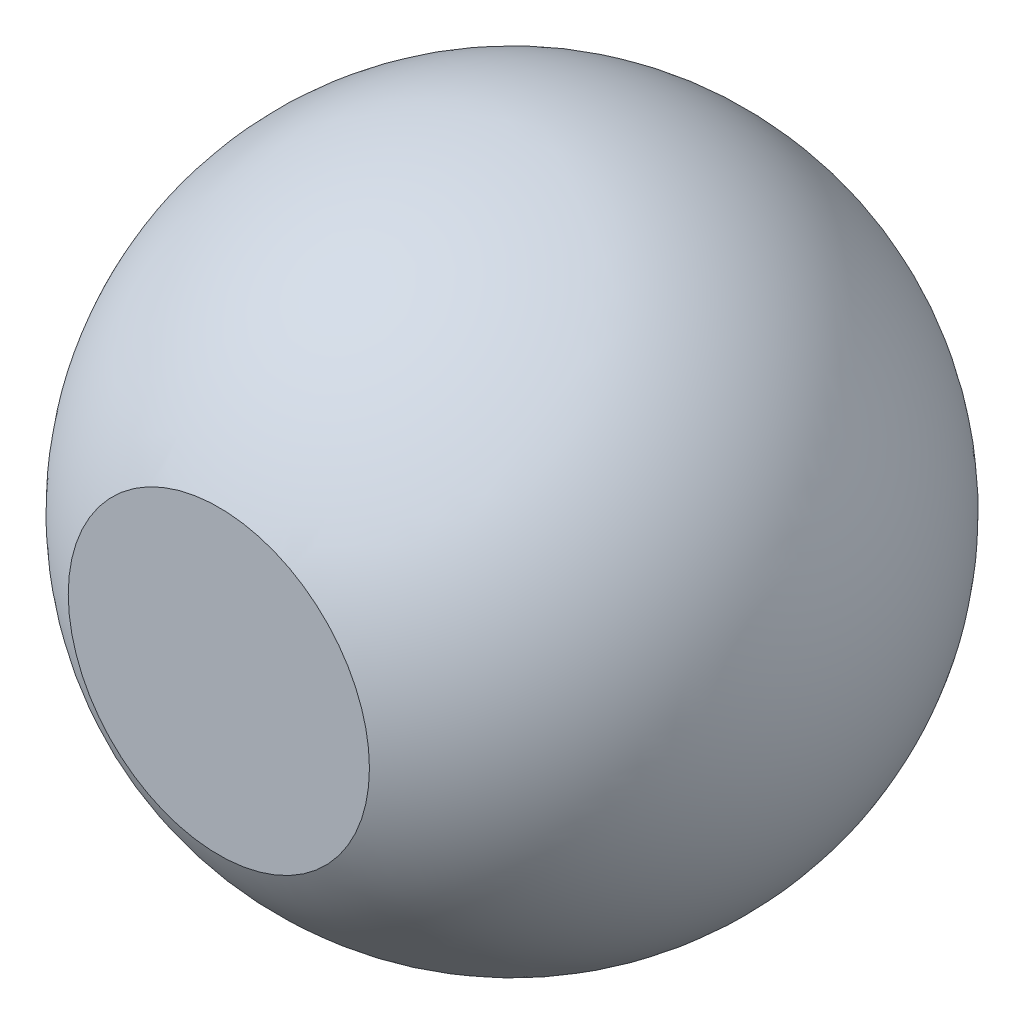
from build123d import *

# Parameters (mm, degrees)
KES_EKSTR_ZYON1_DEPTH      = 10
KES_EKSTR_ZYON1_DEPTH_BACK = 10
IZIM8_W                    = 2.095436062
IZIM8_H                    = 5.184861027
IZIM8_W_2                  = 4.835621684
IZIM8_H_2                  = 1.088014879


with BuildPart() as part:
    # Çizim6 → Döndür1 (revolve)
    with BuildSketch(Plane.XY):
        with BuildLine():
            Line((-4.5, 0), (4.5, 0))
            ThreePointArc((4.5, 0), (0, 4.5), (-4.5, 0))
        make_face()
    revolve(axis=Axis((-4.5, 0, 0), (1, 0, 0)))

    # Çizim8 → Kes-Ekstrüzyon1 (cut, two sides: drawn at the far end of the back side and taken through both)
    with BuildSketch(Plane(origin=(0, 0, 0), x_dir=(0, 0, -1), z_dir=(1, 0, 0)).offset(-KES_EKSTR_ZYON1_DEPTH_BACK)):
        with Locations((-5.050538203, -0.335807062)):
            Rectangle(IZIM8_W, IZIM8_H)
        with Locations((-0.201484237, -4.560259893)):
            Rectangle(IZIM8_W_2, IZIM8_H_2)
    extrude(amount=KES_EKSTR_ZYON1_DEPTH + KES_EKSTR_ZYON1_DEPTH_BACK, mode=Mode.SUBTRACT)


solid = part.part
